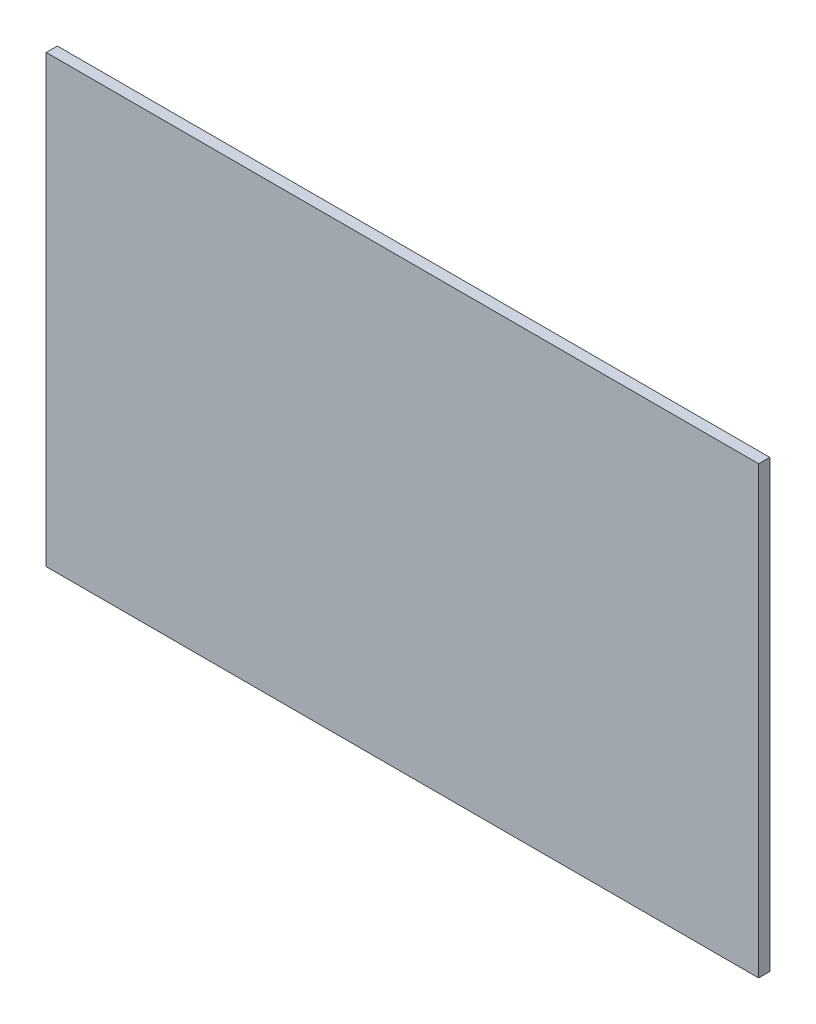
from build123d import *

# Parameters (mm, degrees)
SKETCH1_W           = 406.4
SKETCH1_H           = 254
BOSS_EXTRUDE1_DEPTH = 6.35


with BuildPart() as part:
    # Sketch1 → Boss-Extrude1 (new body)
    with BuildSketch(Plane.XY):
        with Locations((0, 127)):
            Rectangle(SKETCH1_W, SKETCH1_H)
    extrude(amount=BOSS_EXTRUDE1_DEPTH)


solid = part.part
